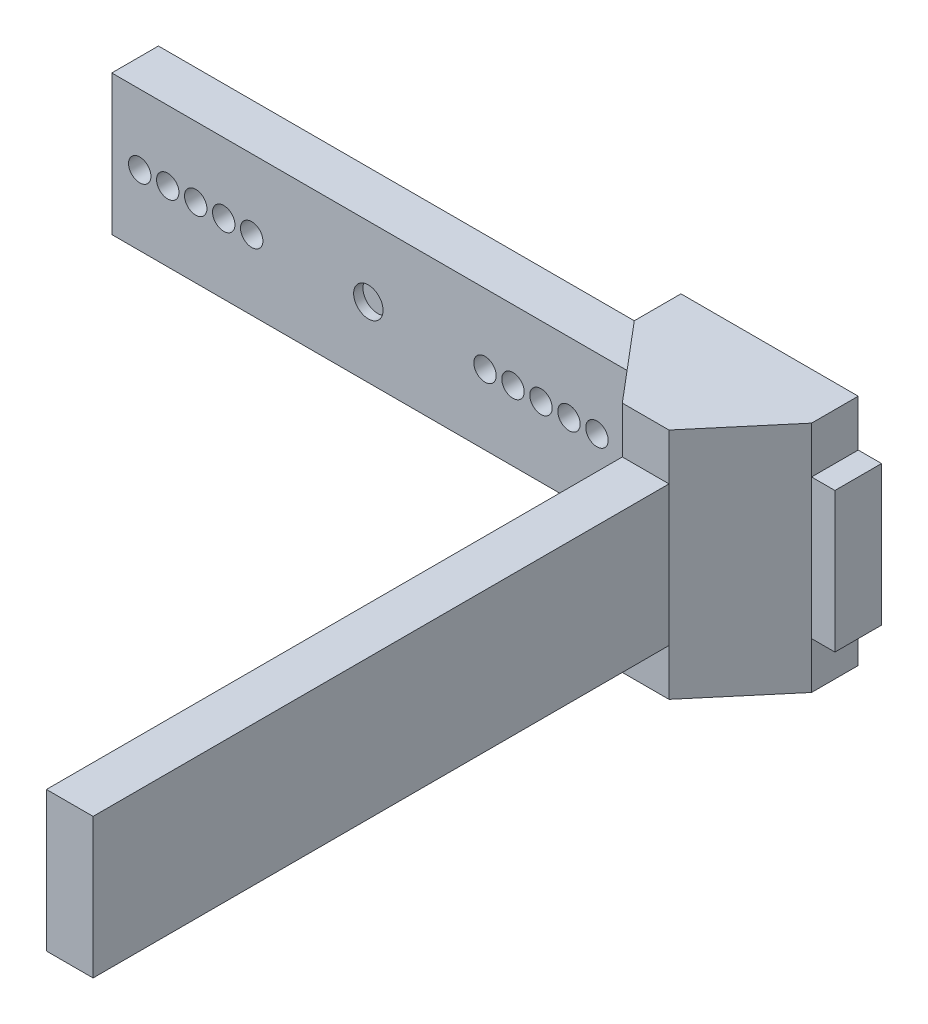
from build123d import *

# Parameters (mm, degrees)
SKETCH1_W           = 55
SKETCH1_H           = 15
SKETCH1_R           = 1.2
SKETCH1_W_2         = 22.5
BOSS_EXTRUDE1_DEPTH = 5
SKETCH2_R           = 1.577401702
CUT_EXTRUDE1_DEPTH  = 1
SKETCH2_3_W         = 5
SKETCH2_3_H         = 15
BOSS_EXTRUDE2_DEPTH = 70
BOSS_EXTRUDE3_DEPTH = 15
BOSS_EXTRUDE4_DEPTH = 5


with BuildPart() as part:
    # Sketch1 → Boss-Extrude1 (new body)
    with BuildSketch(Plane.XY):
        Rectangle(SKETCH1_W, SKETCH1_H)
        with Locations((-15.5, 0)):
            Circle(SKETCH1_R, mode=Mode.SUBTRACT)
        with Locations((-21.5, 0)):
            Circle(SKETCH1_R, mode=Mode.SUBTRACT)
        with Locations((24.5, 0)):
            Circle(SKETCH1_R, mode=Mode.SUBTRACT)
        with Locations((21.5, 0)):
            Circle(SKETCH1_R, mode=Mode.SUBTRACT)
        with Locations((18.5, 0)):
            Circle(SKETCH1_R, mode=Mode.SUBTRACT)
        with Locations((15.5, 0)):
            Circle(SKETCH1_R, mode=Mode.SUBTRACT)
        with Locations((12.5, 0)):
            Circle(SKETCH1_R, mode=Mode.SUBTRACT)
        with Locations((-24.5, 0)):
            Circle(SKETCH1_R, mode=Mode.SUBTRACT)
        with Locations((-18.5, 0)):
            Circle(SKETCH1_R, mode=Mode.SUBTRACT)
        with Locations((-12.5, 0)):
            Circle(SKETCH1_R, mode=Mode.SUBTRACT)
        with Locations((38.75, 0)):
            Rectangle(SKETCH1_W_2, SKETCH1_H)
    extrude(amount=BOSS_EXTRUDE1_DEPTH)

    # Sketch2 → Cut-Extrude1 (cut)
    with BuildSketch(Plane.XY.offset(5)):
        Circle(SKETCH2_R)
    extrude(amount=-CUT_EXTRUDE1_DEPTH, mode=Mode.SUBTRACT)

    # Sketch2_3 → Boss-Extrude2 (add)
    with BuildSketch(Plane.XY.offset(5)):
        with Locations((38, 0)):
            Rectangle(SKETCH2_3_W, SKETCH2_3_H)
    extrude(amount=BOSS_EXTRUDE2_DEPTH)

    # Sketch6 → Boss-Extrude3 (add)
    with BuildSketch(Plane(origin=(0, 7.5, 0), x_dir=(1, 0, 0), z_dir=(0, 1, 0))):
        Polygon((28.5, -5), (35.5, -13.282174024), (35.5, -5), align=None)
    boss_extrude3 = extrude(amount=-BOSS_EXTRUDE3_DEPTH)

    # Mirror1: Boss-Extrude3 across plane
    add(boss_extrude3.mirror(Plane(origin=(38, 0, 0), x_dir=(0, 0, 1), z_dir=(1, 0, 0))))

    # Sketch7 → Boss-Extrude4 (add)
    with BuildSketch(Plane(origin=(0, 7.5, 0), x_dir=(1, 0, 0), z_dir=(0, 1, 0))):
        Polygon((35.5, -13.282174024), (28.5, -5), (28.5, 0), (47.5, 0), (47.5, -5), (40.5, -13.282174024), align=None)
    boss_extrude4 = extrude(amount=BOSS_EXTRUDE4_DEPTH)

    # Mirror2: Boss-Extrude4 across plane
    add(boss_extrude4.mirror(Plane(origin=(0, 0, 0), x_dir=(0, 0, 1), z_dir=(0, -1, 0))))


solid = part.part
